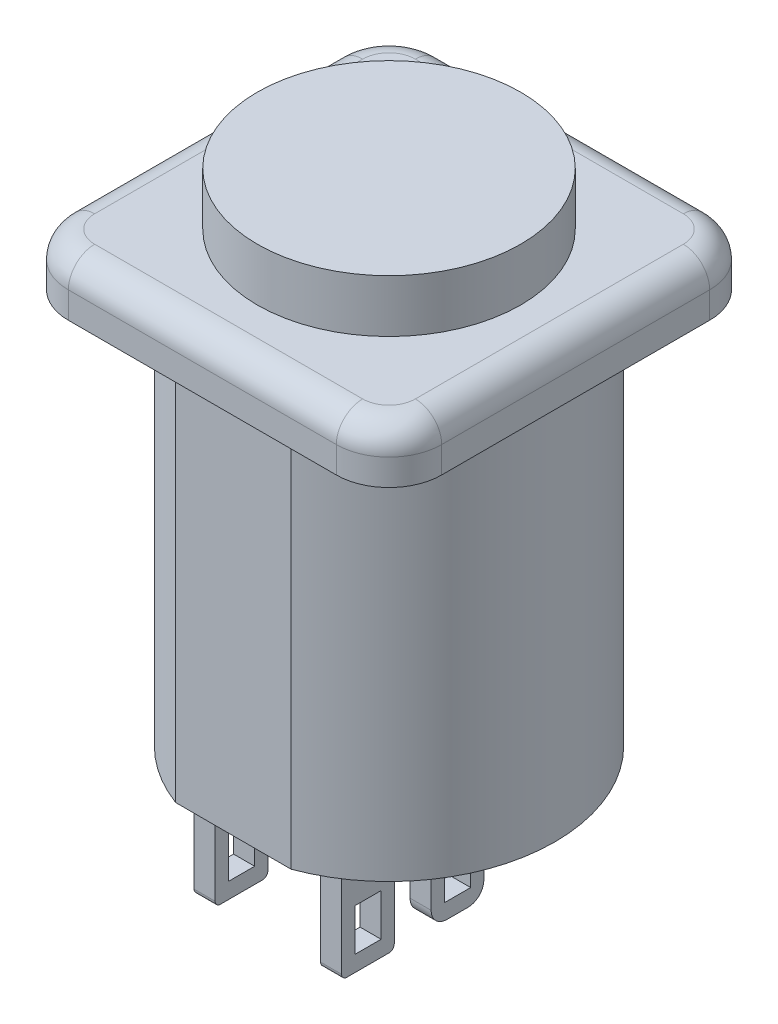
from build123d import *

# Parameters (mm, degrees)
BOSS_EXTRUDE1_DEPTH   = 19.05
SKETCH2_W             = 18
SKETCH2_H             = 18
BOSS_EXTRUDE2_DEPTH   = 2.54
FILLET1_R             = 2.54
FILLET2_R             = 1.27
SKETCH3_R             = 6.35
BOSS_EXTRUDE3_DEPTH   = 2.54
SKETCH4_W             = 1.016
SKETCH4_H             = 2.54
BOSS_EXTRUDE5_DEPTH   = 5.08
BOSS_EXTRUDE5_2_DEPTH = 5.08
BOSS_EXTRUDE5_3_DEPTH = 5.08
BOSS_EXTRUDE5_4_DEPTH = 5.08
SKETCH5_W             = 1.27
SKETCH5_H             = 2.032
CUT_EXTRUDE1_DEPTH    = 8.128
FILLET3_R             = 0.254
FILLET4_R             = 0.254
FILLET5_R             = 0.762
FILLET6_R             = 0.762


with BuildPart() as part:
    # Sketch1 → Boss-Extrude1 (new body)
    with BuildSketch(Plane(origin=(0, 0, 0), x_dir=(1, 0, 0), z_dir=(0, 1, 0))):
        with BuildLine():
            Line((-2.783882181, 7.5), (2.783882181, 7.5))
            ThreePointArc((2.783882181, 7.5), (8, 0), (2.783882181, -7.5))
            Line((2.783882181, -7.5), (-2.783882181, -7.5))
            ThreePointArc((-2.783882181, -7.5), (-8, 0), (-2.783882181, 7.5))
        make_face()
    extrude(amount=BOSS_EXTRUDE1_DEPTH)

    # Sketch2 → Boss-Extrude2 (add)
    with BuildSketch(Plane(origin=(0, 19.05, 0), x_dir=(1, 0, 0), z_dir=(0, 1, 0))):
        Rectangle(SKETCH2_W, SKETCH2_H)
    extrude(amount=BOSS_EXTRUDE2_DEPTH)

    # Fillet1
    fillet1_edges = [part.edges().sort_by_distance(p)[0] for p in [
        (-9, 20.32, -9),
        (-9, 20.32, 9),
        (9, 20.32, 9),
        (9, 20.32, -9),
    ]]
    fillet(fillet1_edges, radius=FILLET1_R)

    # Fillet2
    fillet2_edges = [part.edges().sort_by_distance(p)[0] for p in [
        (0, 21.59, -9),
        (9, 21.59, 0),
        (-9, 21.59, 0),
        (0, 21.59, 9),
        (8.256051224, 21.59, 8.256051224),
        (-8.256051224, 21.59, 8.256051224),
        (-8.256051224, 21.59, -8.256051224),
        (8.256051224, 21.59, -8.256051224),
    ]]
    fillet(fillet2_edges, radius=FILLET2_R)


with BuildPart() as body_2:
    # Sketch3 → Boss-Extrude3 (new body)
    with BuildSketch(Plane(origin=(0, 21.59, 0), x_dir=(1, 0, 0), z_dir=(0, 1, 0))):
        Circle(SKETCH3_R)
    extrude(amount=BOSS_EXTRUDE3_DEPTH)


with BuildPart() as body_3:
    # Sketch4 → Boss-Extrude5 (new body)
    with BuildSketch(Plane.XZ):
        with Locations((3.048, 0.254)):
            Rectangle(SKETCH4_W, SKETCH4_H)
    extrude(amount=BOSS_EXTRUDE5_DEPTH)


with BuildPart() as body_4:
    # Sketch4 → Boss-Extrude5 2 (new body)
    with BuildSketch(Plane.XZ):
        with Locations((-3.048, 4.572)):
            Rectangle(SKETCH4_W, SKETCH4_H)
    extrude(amount=BOSS_EXTRUDE5_2_DEPTH)


with BuildPart() as body_5:
    # Sketch4 → Boss-Extrude5 3 (new body)
    with BuildSketch(Plane.XZ):
        with Locations((-3.048, 0.254)):
            Rectangle(SKETCH4_W, SKETCH4_H)
    extrude(amount=BOSS_EXTRUDE5_3_DEPTH)


with BuildPart() as body_6:
    # Sketch4 → Boss-Extrude5 4 (new body)
    with BuildSketch(Plane.XZ):
        with Locations((3.048, 4.572)):
            Rectangle(SKETCH4_W, SKETCH4_H)
    extrude(amount=BOSS_EXTRUDE5_4_DEPTH)


with BuildPart() as cut_extrude1_tool:
    # Sketch5 → Cut-Extrude1 (new body)
    with BuildSketch(Plane.ZY.offset(3.556)):
        with Locations((4.572, -3.302)):
            Rectangle(SKETCH5_W, SKETCH5_H)
        with Locations((0.254, -3.302)):
            Rectangle(SKETCH5_W, SKETCH5_H)
    extrude(amount=-CUT_EXTRUDE1_DEPTH)


with BuildPart() as body_3_1:
    add(body_3.part)

    # Cut-Extrude1: cut by cut_extrude1_tool
    add(cut_extrude1_tool.part, mode=Mode.SUBTRACT)

    # Fillet6
    fillet6_edges = [body_3_1.edges().sort_by_distance(p)[0] for p in [
        (3.048, -5.08, -1.016),
        (3.048, -5.08, 1.524),
    ]]
    fillet(fillet6_edges, radius=FILLET6_R)


with BuildPart() as body_4_1:
    add(body_4.part)

    # Cut-Extrude1: cut by cut_extrude1_tool
    add(cut_extrude1_tool.part, mode=Mode.SUBTRACT)

    # Fillet3
    fillet3_edges = [body_4_1.edges().sort_by_distance(p)[0] for p in [
        (-3.048, -5.08, 5.842),
        (-3.048, -5.08, 3.302),
    ]]
    fillet(fillet3_edges, radius=FILLET3_R)


with BuildPart() as body_5_1:
    add(body_5.part)

    # Cut-Extrude1: cut by cut_extrude1_tool
    add(cut_extrude1_tool.part, mode=Mode.SUBTRACT)

    # Fillet5
    fillet5_edges = [body_5_1.edges().sort_by_distance(p)[0] for p in [
        (-3.048, -5.08, 1.524),
        (-3.048, -5.08, -1.016),
    ]]
    fillet(fillet5_edges, radius=FILLET5_R)


with BuildPart() as body_6_1:
    add(body_6.part)

    # Cut-Extrude1: cut by cut_extrude1_tool
    add(cut_extrude1_tool.part, mode=Mode.SUBTRACT)

    # Fillet4
    fillet4_edges = [body_6_1.edges().sort_by_distance(p)[0] for p in [
        (3.048, -5.08, 3.302),
        (3.048, -5.08, 5.842),
    ]]
    fillet(fillet4_edges, radius=FILLET4_R)


solid = Compound([part.part, body_2.part, body_3_1.part, body_4_1.part, body_5_1.part, body_6_1.part])
